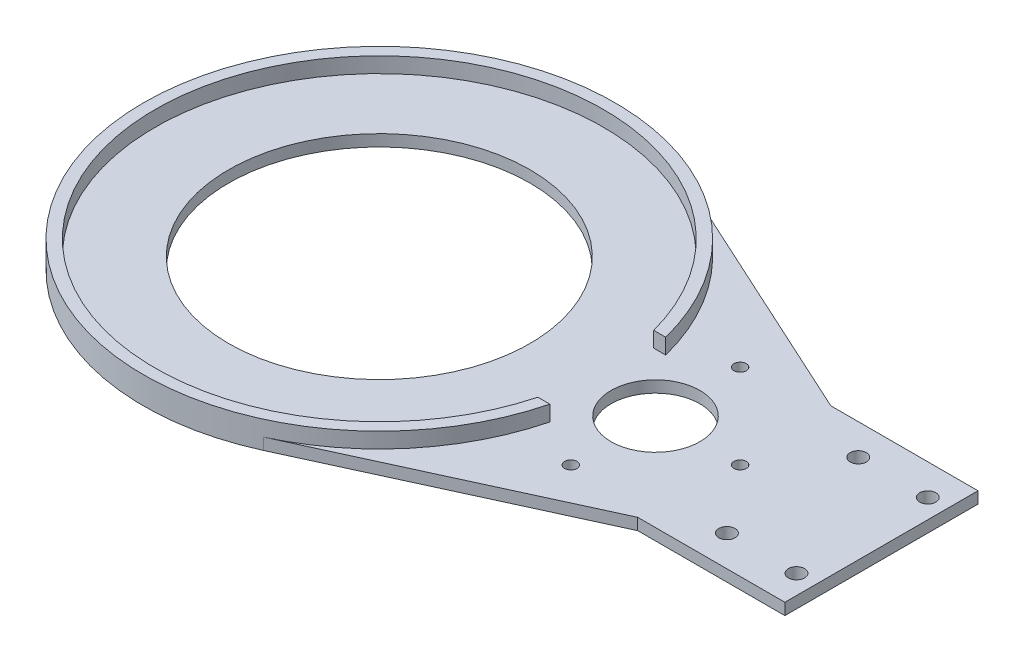
from build123d import *

# Parameters (mm, degrees)
EXTRUDE_3_DEPTH     = 3
SKETCH_3_R          = 11.5
SKETCH_3_R_2        = 39
SKETCH_3_R_3        = 1.6
SKETCH_3_R_4        = 2.1
CUT_EXTRUDE_1_DEPTH = 4
SKETCH_4_W          = 3
SKETCH_4_H          = 4
SKETCH_6_W          = 30
SKETCH_6_H          = 10
CUT_EXTRUDE_3_DEPTH = 10


with BuildPart() as part:
    # 草图2 → 凸台-拉伸3 (new body)
    with BuildSketch(Plane(origin=(0, 0, 0), x_dir=(1, 0, 0), z_dir=(0, 1, 0))):
        with BuildLine():
            Line((91.901888805, 25), (25.431682676, 55.473238064))
            ThreePointArc((25.431682676, 55.473238064), (-61.025, 0), (25.431682676, -55.473238064))
            Line((25.431682676, -55.473238064), (91.901888805, -25))
            Line((91.901888805, -25), (130, -25))
            Line((130, -25), (130, 25))
            Line((130, 25), (91.901888805, 25))
        make_face()
    extrude(amount=EXTRUDE_3_DEPTH)

    # 草图3 → 切除-拉伸1 (cut, through all)
    with BuildSketch(Plane(origin=(0, 3, 0), x_dir=(1, 0, 0), z_dir=(0, 1, 0))):
        with Locations((71.5, 0)):
            Circle(SKETCH_3_R)
        Circle(SKETCH_3_R_2)
        with Locations((71.5, 21.917)):
            Circle(SKETCH_3_R_3)
        with Locations((93.417, 0)):
            Circle(SKETCH_3_R_3)
        with Locations((71.5, -21.917)):
            Circle(SKETCH_3_R_3)
        with Locations((125, 17)):
            Circle(SKETCH_3_R_4)
        with Locations((107, 17)):
            Circle(SKETCH_3_R_4)
        with Locations((125, -17)):
            Circle(SKETCH_3_R_4)
        with Locations((107, -17)):
            Circle(SKETCH_3_R_4)
    extrude(amount=-CUT_EXTRUDE_1_DEPTH, mode=Mode.SUBTRACT)

    # 草图4 → 旋转1 (revolve)
    with BuildSketch(Plane.XY):
        with Locations((-59.525, 5)):
            Rectangle(SKETCH_4_W, SKETCH_4_H)
    revolve(axis=Axis((0, 38.176517008, 0), (0, -1, 0)))

    # 草图6 → 切除-拉伸3 (cut)
    with BuildSketch(Plane(origin=(61.025, 0, 0), x_dir=(0, 0, -1), z_dir=(1, 0, 0))):
        with Locations((0, 8)):
            Rectangle(SKETCH_6_W, SKETCH_6_H)
    extrude(amount=-CUT_EXTRUDE_3_DEPTH, mode=Mode.SUBTRACT)


solid = part.part
